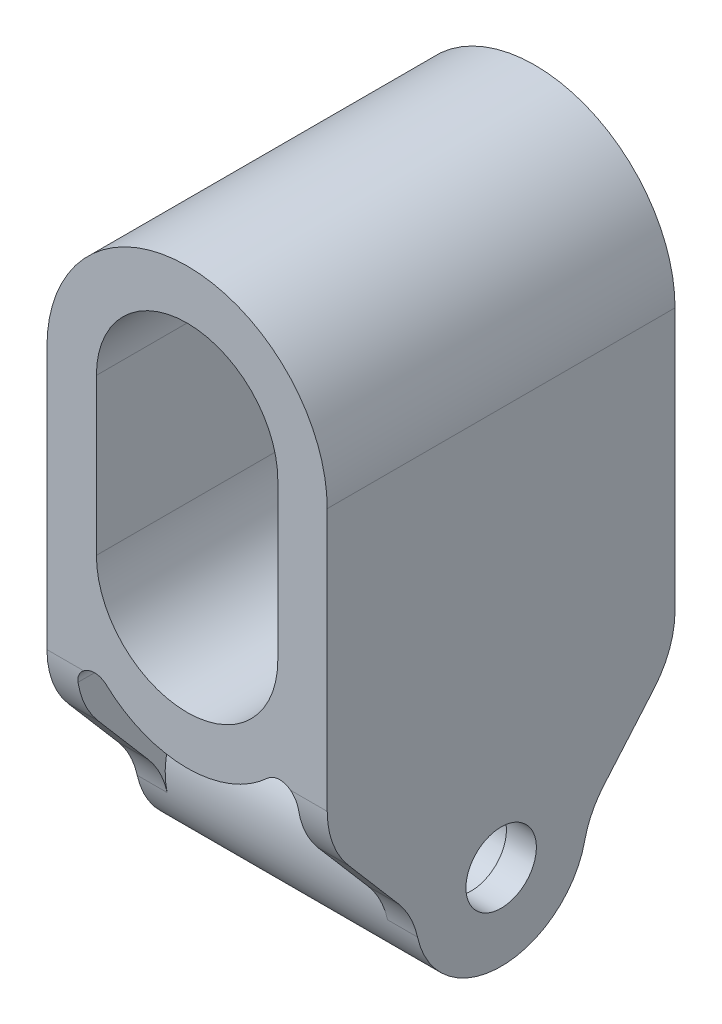
from build123d import *

# Parameters (mm, degrees)
BOSS_EXTRUDE1_DEPTH  = 39.5
CUT_EXTRUDE1_DEPTH   = 75.75264493648368
M7_CLEARANCE_HOLE1_D = 8
FILLET1_R            = 10
FILLET3_R            = 2
BOSS_EXTRUDE2_REACH  = 76.753
SKETCH3_3_R          = 9.724999999999993
SKETCH3_3_R_2        = 4.4


with BuildPart() as part:
    # Sketch2 → Boss-Extrude1 (new body)
    with BuildSketch(Plane.XY):
        with BuildLine():
            Line((-15.914999999999996, 0), (-15.914999999999988, -54.904999999999994))
            Line((-15.914999999999988, -54.904999999999994), (-12.514999999999986, -54.904999999999994))
            Line((-12.514999999999986, -54.904999999999994), (-12.515, -25))
            ThreePointArc((-12.515, -25), (4.71e-15, -33.47684031960013), (12.515, -25))
            Line((12.515, -25), (12.515000000000002, -54.904999999999994))
            Line((12.515000000000002, -54.904999999999994), (15.915, -54.904999999999994))
            Line((15.915, -54.904999999999994), (15.914999999999996, 3.9e-15))
            ThreePointArc((15.914999999999996, 3.9e-15), (9.7e-16, 15.914999999999996), (-15.914999999999996, 0))
        make_face()
        with BuildLine():
            Line((10.3, 1.26e-15), (10.3, -17.7))
            ThreePointArc((10.3, -17.7), (3.82e-15, -28), (-10.299999999999997, -17.700000000000003))
            Line((-10.299999999999997, -17.700000000000003), (-10.3, -1.26e-15))
            ThreePointArc((-10.3, -1.26e-15), (-1.66e-15, 10.3), (10.3, 1.26e-15))
        make_face(mode=Mode.SUBTRACT)
    extrude(amount=BOSS_EXTRUDE1_DEPTH)

    # Sketch3 → Cut-Extrude1 (cut, through all)
    with BuildSketch(Plane.ZY.offset(15.914999999999996)):
        with BuildLine():
            Line((0, -54.904999999999994), (19.74999999999999, -54.904999999999994))
            ThreePointArc((19.74999999999999, -54.904999999999994), (12.873386552960827, -52.05661344703917), (10.025000000000007, -45.18))
            Line((10.025, -45.18), (0, -33.47684031960014))
            Line((0, -33.47684031960014), (0, -54.904999999999994))
        make_face()
        with BuildLine():
            Line((19.74999999999999, -54.904999999999994), (39.5, -54.904999999999994))
            Line((39.5, -54.904999999999994), (39.5, -33.47684031960014))
            Line((39.5, -33.47684031960014), (29.475, -45.18))
            ThreePointArc((29.474999999999994, -45.18), (26.626613447039162, -52.056613447039176), (19.74999999999999, -54.904999999999994))
        make_face()
    extrude(amount=-CUT_EXTRUDE1_DEPTH, mode=Mode.SUBTRACT)

    # M7 Clearance Hole1 (through all)
    with Locations(Plane.ZY.offset(15.914999999999996)):
        with Locations((19.75, -45.18)):
            Hole(M7_CLEARANCE_HOLE1_D / 2)

    # Fillet1
    fillet1_edges = [part.edges().sort_by_distance(p)[0] for p in [
        (-14.21499999999999, -45.18, 10.025000000000002),
        (14.215000000000002, -45.17999999999999, 10.025000000000002),
        (-14.214999999999993, -33.47684031960014, 0),
        (14.215, -33.476840319600136, 0),
        (-14.21499999999999, -45.18, 29.474999999999998),
        (14.215000000000002, -45.17999999999999, 29.474999999999998),
        (-14.214999999999993, -33.47684031960014, 39.5),
        (14.215, -33.476840319600136, 39.5),
    ]]
    fillet(fillet1_edges, radius=FILLET1_R)

    # Fillet3
    fillet3_edges = [part.edges().sort_by_distance(p)[0] for p in [
        (12.515, -25, 19.75),
        (-12.515000000000002, -25, 19.75),
    ]]
    fillet(fillet3_edges, radius=FILLET3_R)

    # Boss-Extrude2: up to this face of the body (flat: up to its plane)
    boss_extrude2_end = Plane(part.part.faces().sort_by_distance((12.515, -40.102126489, 19.75))[0])
    # Sketch3_3 → Boss-Extrude2 (add, up to the picked face)
    with BuildSketch(Plane.ZY.offset(15.914999999999996), mode=Mode.PRIVATE) as boss_extrude2_sk1:
        with Locations((19.75, -45.18)):
            Circle(SKETCH3_3_R)
        with Locations(Location((19.75, -45.18, 0), (0, 0, 270))):
            Circle(SKETCH3_3_R_2, mode=Mode.SUBTRACT)
    boss_extrude2_tool1 = split(extrude(boss_extrude2_sk1.sketch, amount=-BOSS_EXTRUDE2_REACH, mode=Mode.PRIVATE), bisect_by=boss_extrude2_end, keep=Keep.BOTH, mode=Mode.PRIVATE)
    # Sketch3_3 → Boss-Extrude2 (add, up to the picked face)
    with BuildSketch(Plane.ZY.offset(15.914999999999996), mode=Mode.PRIVATE) as boss_extrude2_sk2:
        with BuildLine():
            Line((17.206534975176847, -35.77037402891417), (17.293465024823192, -35.77037402891417))
            ThreePointArc((17.293465024823192, -35.77037402891417), (19.750000000000018, -35.455000000000005), (22.206534975176844, -35.770374028914176))
            Line((22.206534975176847, -35.77037402891417), (22.206534975176847, -28.83040215808249))
            ThreePointArc((22.20653497517679, -28.830402158082467), (19.697179052869707, -29.57968293716084), (17.20653497517685, -28.770374028914166))
            Line((17.206534975176847, -28.77037402891417), (17.206534975176847, -35.77037402891417))
        make_face()
    boss_extrude2_tool2 = split(extrude(boss_extrude2_sk2.sketch, amount=-BOSS_EXTRUDE2_REACH, mode=Mode.PRIVATE), bisect_by=boss_extrude2_end, keep=Keep.BOTH, mode=Mode.PRIVATE)
    # Sketch3_3 → Boss-Extrude2 (add, up to the picked face)
    with BuildSketch(Plane.ZY.offset(15.914999999999996), mode=Mode.PRIVATE) as boss_extrude2_sk3:
        with BuildLine():
            ThreePointArc((22.206534975176844, -35.770374028914176), (19.750000000000018, -35.455000000000005), (17.293465024823192, -35.77037402891417))
            Line((17.293465024823192, -35.77037402891417), (22.206534975176847, -35.77037402891417))
        make_face()
    boss_extrude2_tool3 = split(extrude(boss_extrude2_sk3.sketch, amount=-BOSS_EXTRUDE2_REACH, mode=Mode.PRIVATE), bisect_by=boss_extrude2_end, keep=Keep.BOTH, mode=Mode.PRIVATE)
    add(boss_extrude2_tool1.solids().sort_by(Axis((-15.915, -45.18, 10.300065), (1, 1.9e-16, 0)))[0])
    add(boss_extrude2_tool2.solids().sort_by(Axis((-15.915, -32.443059, 19.701397), (1, 1.9e-16, 0)))[0])
    add(boss_extrude2_tool3.solids().sort_by(Axis((-15.915, -35.644047, 19.75), (1, 1.9e-16, 0)))[0])


solid = part.part
